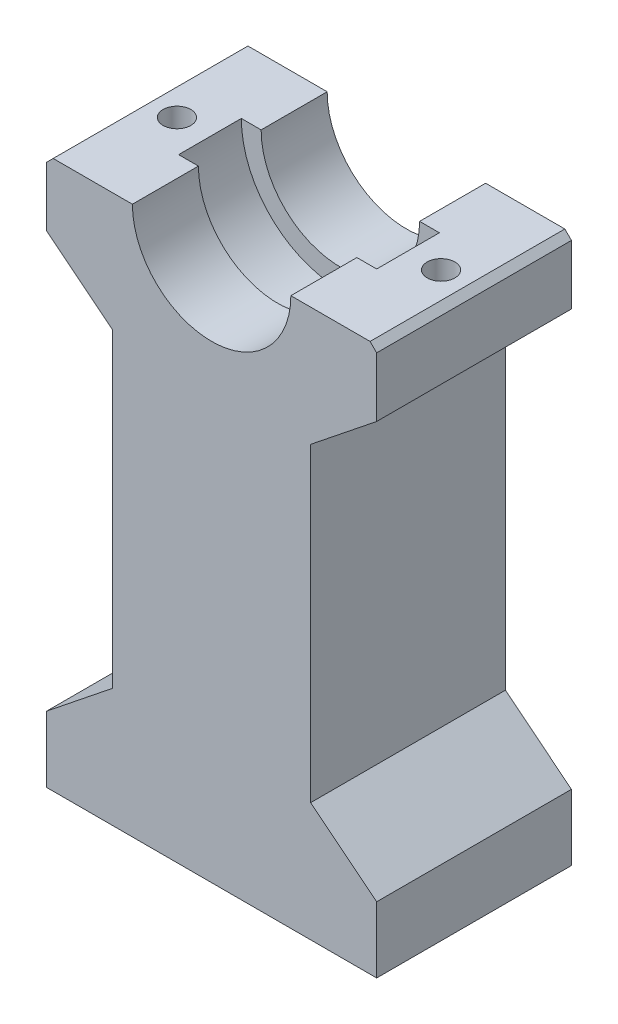
from build123d import *

# Parameters (mm, degrees)
BOSS_EXTRUDE1_DEPTH = 29.5
BOSS_EXTRUDE2_DEPTH = 7
CHAMFER1_SIZE       = 0.5
M5X0_82_D           = 4.2
M5X0_82_DEPTH       = 19
M5X0_82_TIP         = 1.2618073
SKETCH13_W          = 8.675232358
SKETCH13_H          = 9.5
M5X0_81_REACH       = 99.955
M5X0_81_BORE_R      = 2.1
CHAMFER_1_SIZE      = 1


with BuildPart() as part:
    # Sketch1 → Boss-Extrude1 (new body)
    with BuildSketch(Plane.XY):
        with BuildLine():
            Line((12, 0), (25, 0))
            Line((25, 0), (25, -10))
            Line((25, -10), (15, -18))
            Line((15, -18), (15, -65))
            Line((15, -65), (25, -73))
            Line((25, -73), (25, -83))
            Line((25, -83), (-25, -83))
            Line((-25, -83), (-25, -73))
            Line((-25, -73), (-15, -65))
            Line((-15, -65), (-15, -18))
            Line((-15, -18), (-25, -10))
            Line((-25, -10), (-25, 0))
            Line((-25, 0), (-12, 0))
            ThreePointArc((-12, 0), (0, -12), (12, 0))
        make_face()
    extrude(amount=BOSS_EXTRUDE1_DEPTH)

    # Sketch2 → Boss-Extrude2 (add)
    with BuildSketch(Plane.XZ.offset(83)):
        with BuildLine():
            Line((-10, 12.275), (10, 12.275))
            ThreePointArc((10, 12.275), (12.475, 14.75), (10, 17.225))
            Line((10, 17.225), (-10, 17.225))
            ThreePointArc((-10, 17.225), (-12.475, 14.75), (-10, 12.275))
        make_face()
    extrude(amount=BOSS_EXTRUDE2_DEPTH)

    # Chamfer1
    chamfer1_edges = [part.edges().sort_by_distance(p)[0] for p in [
        (12.475, -90, 14.75),
        (0, -90, 17.225),
        (-12.475, -90, 14.75),
        (0, -90, 12.275),
    ]]
    chamfer(chamfer1_edges, length=CHAMFER1_SIZE)

    # Отверстие обработанное метчиком M5x0.82
    with Locations(Plane(origin=(0, -83, 0), x_dir=(-1, 0, 0), z_dir=(0, -1, 0))):
        with Locations((0, -23.3625), (0, -6.1375)):
            Hole(M5X0_82_D / 2, depth=M5X0_82_DEPTH)
            with Locations((0, 0, -(M5X0_82_DEPTH + M5X0_82_TIP / 2))):  # 118° drill point
                Cone(0, M5X0_82_D / 2, M5X0_82_TIP, mode=Mode.SUBTRACT)

    # Sketch13 → Cut-Revolve1 (revolve, cut)
    with BuildSketch(Plane(origin=(0, 0, 0), x_dir=(1, 0, 0), z_dir=(0, 1, 0))):
        with Locations((-10.662383821, -14.75)):
            Rectangle(SKETCH13_W, SKETCH13_H)
    revolve(axis=Axis((0, 0, 0), (0, 0, 1)), mode=Mode.SUBTRACT)

    # Отверстие обработанное метчиком M5x0.81 bore → Отверстие обработанное метчиком M5x0.81 (cut, up to next)
    with BuildSketch(Plane(origin=(0, 0, 0), x_dir=(1, 0, 0), z_dir=(0, 1, 0)), mode=Mode.PRIVATE) as m5x0_81_sk1:
        with Locations((-20, -14.75)):
            Circle(M5X0_81_BORE_R)
    m5x0_81_tool1 = extrude(m5x0_81_sk1.sketch, amount=-M5X0_81_REACH, mode=Mode.PRIVATE) & part.part
    # Отверстие обработанное метчиком M5x0.81 bore → Отверстие обработанное метчиком M5x0.81 (cut, up to next)
    with BuildSketch(Plane(origin=(0, 0, 0), x_dir=(1, 0, 0), z_dir=(0, 1, 0)), mode=Mode.PRIVATE) as m5x0_81_sk2:
        with Locations((20, -14.75)):
            Circle(M5X0_81_BORE_R)
    m5x0_81_tool2 = extrude(m5x0_81_sk2.sketch, amount=-M5X0_81_REACH, mode=Mode.PRIVATE) & part.part
    add(m5x0_81_tool1.solids().sort_by_distance((-20, 0, 14.75))[0], mode=Mode.SUBTRACT)
    add(m5x0_81_tool2.solids().sort_by_distance((20, 0, 14.75))[0], mode=Mode.SUBTRACT)

    # Фаска1
    chamfer_1_edges = [part.edges().sort_by_distance(p)[0] for p in [
        (-25, 0, 14.75),
        (25, 0, 14.75),
    ]]
    chamfer(chamfer_1_edges, length=CHAMFER_1_SIZE)


solid = part.part
